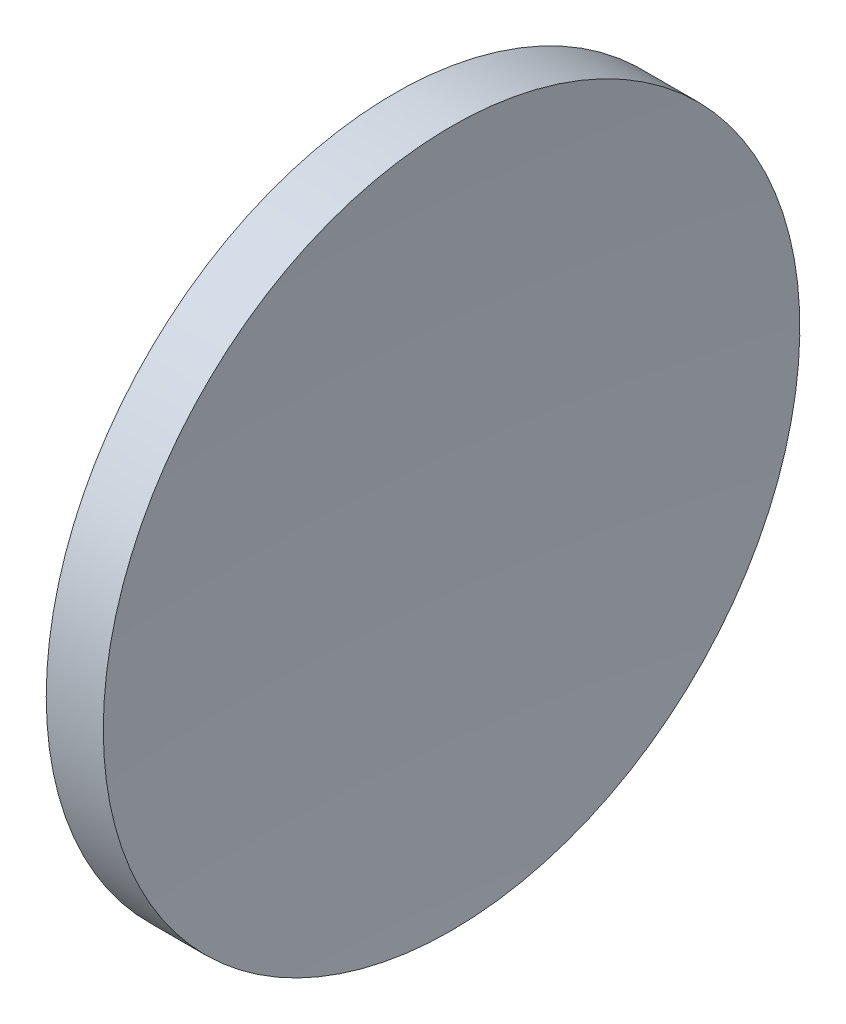
from build123d import *


with BuildPart() as part:
    # 草图1 → 旋转1 (revolve)
    with BuildSketch(Plane.XY, mode=Mode.PRIVATE) as revolve_1_sk:
        with BuildLine():
            Line((113.911931674, 65.155630457), (113.911931674, 85.155630457))
            Line((113.911931674, 85.155630457), (117.187750667, 85.155630457))
            ThreePointArc((117.187750667, 85.155630457), (116.60595933, 75.163151318), (116.411931674, 65.155630457))
            Line((116.411931674, 65.155630457), (113.911931674, 65.155630457))
        make_face()
    revolve(revolve_1_sk.sketch.rotate(Axis((105.621837124, 65.155630457, 0), (1, 0, 0)), 180), axis=Axis((105.621837124, 65.155630457, 0), (1, 0, 0)))  # turned: the seam where the file's is


solid = part.part
